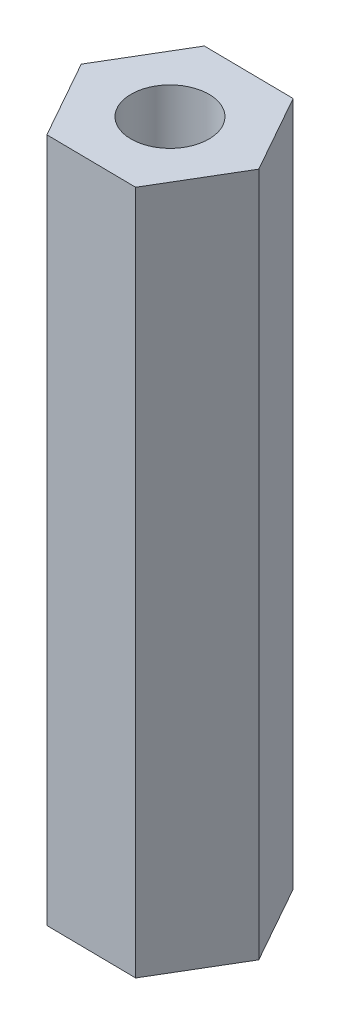
from build123d import *

# Parameters (mm, degrees)
BOSS_EXTRUDE1_DEPTH       = 22
M3X0_5_TAPPED_HOLE1_D     = 2.5
M3X0_5_TAPPED_HOLE1_DEPTH = 22


with BuildPart() as part:
    # Sketch1 → Boss-Extrude1 (new body)
    with BuildSketch(Plane(origin=(0, 0, 0), x_dir=(1, 0, 0), z_dir=(0, 1, 0))):
        Polygon((1.413165118, -2.517200366), (2.886542022, -0.034763291), (1.473376905, 2.482437075), (-1.413165118, 2.517200366), (-2.886542022, 0.034763291), (-1.473376905, -2.482437075), align=None)
    extrude(amount=BOSS_EXTRUDE1_DEPTH)

    # M3x0.5 Tapped Hole1
    with Locations(Plane(origin=(0, 22, 0), x_dir=(1, 0, 0), z_dir=(0, 1, 0))):
        with Locations((0, 0)):
            Hole(M3X0_5_TAPPED_HOLE1_D / 2, depth=M3X0_5_TAPPED_HOLE1_DEPTH)


solid = part.part
